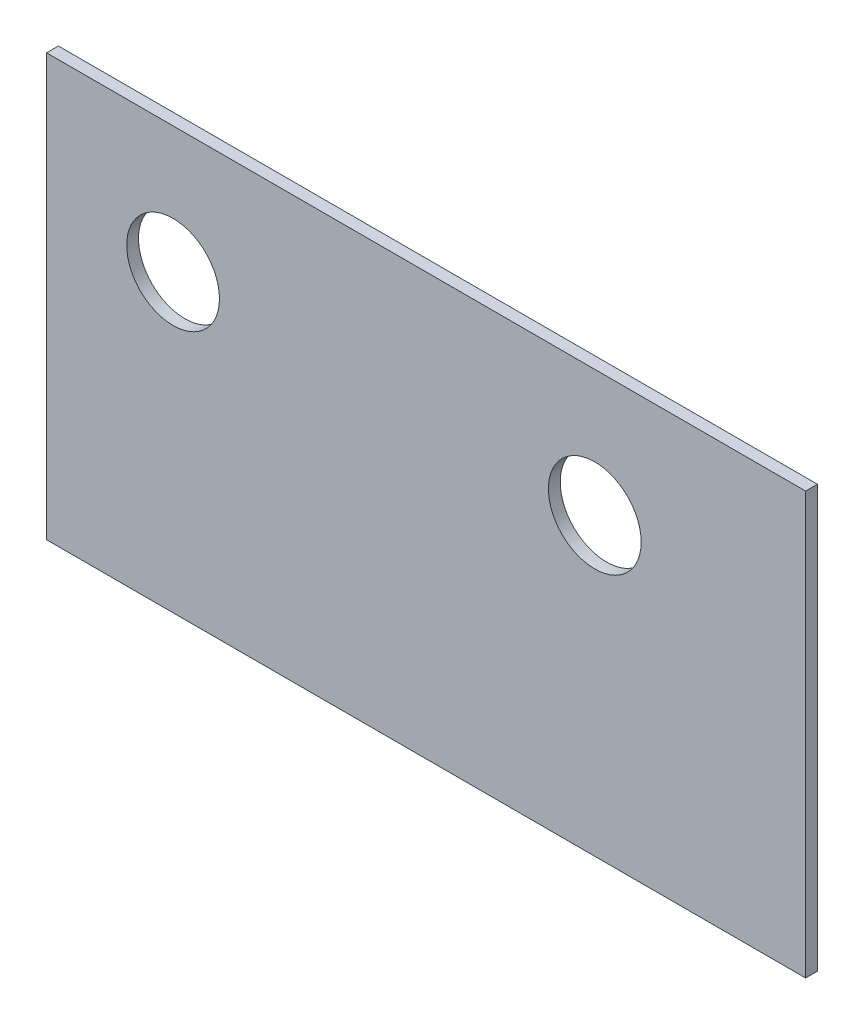
from build123d import *

# Parameters (mm, degrees)
SKETCH1_W           = 180
SKETCH1_H           = 100
SKETCH1_R           = 11
BOSS_EXTRUDE1_DEPTH = 2.8


with BuildPart() as part:
    # Sketch1 → Boss-Extrude1 (new body)
    with BuildSketch(Plane.XY):
        with Locations((90, 50)):
            Rectangle(SKETCH1_W, SKETCH1_H)
        with Locations((30, 70)):
            Circle(SKETCH1_R, mode=Mode.SUBTRACT)
        with Locations((130, 70)):
            Circle(SKETCH1_R, mode=Mode.SUBTRACT)
    extrude(amount=BOSS_EXTRUDE1_DEPTH)


solid = part.part
